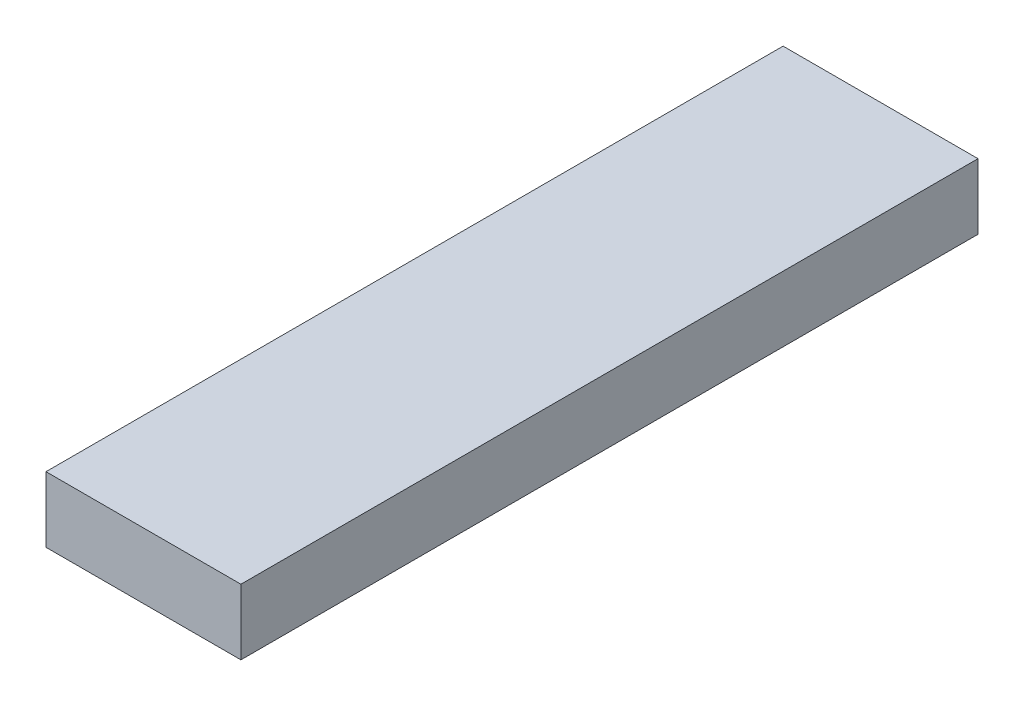
from build123d import *

# Parameters (mm, degrees)
SKETCH1_W           = 11.9
SKETCH1_H           = 45
BOSS_EXTRUDE1_DEPTH = 4


with BuildPart() as part:
    # Sketch1 → Boss-Extrude1 (new body)
    with BuildSketch(Plane(origin=(0, 0, 0), x_dir=(1, 0, 0), z_dir=(0, 1, 0))):
        Rectangle(SKETCH1_W, SKETCH1_H)
    extrude(amount=BOSS_EXTRUDE1_DEPTH)


solid = part.part
